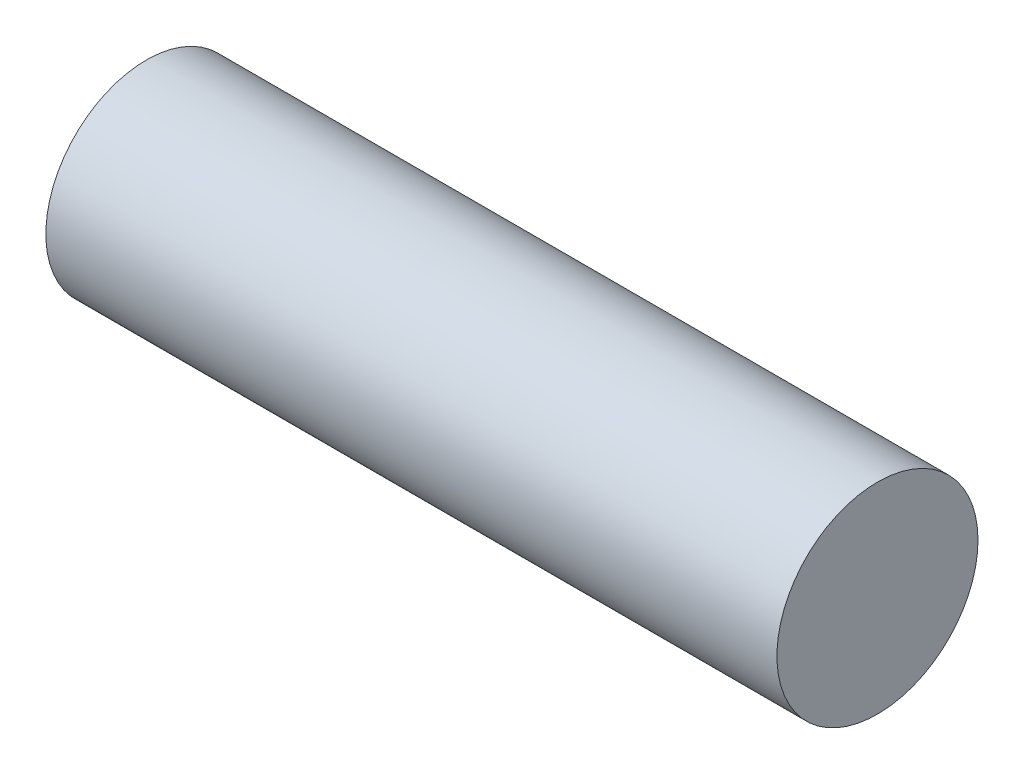
from build123d import *

# Parameters (mm, degrees)
SKETCH1_R           = 55
BOSS_EXTRUDE1_DEPTH = 400


with BuildPart() as part:
    # Sketch1 → Boss-Extrude1 (new body)
    with BuildSketch(Plane(origin=(0, 0, 0), x_dir=(0, 0, -1), z_dir=(1, 0, 0))):
        Circle(SKETCH1_R)
    extrude(amount=BOSS_EXTRUDE1_DEPTH)


solid = part.part
